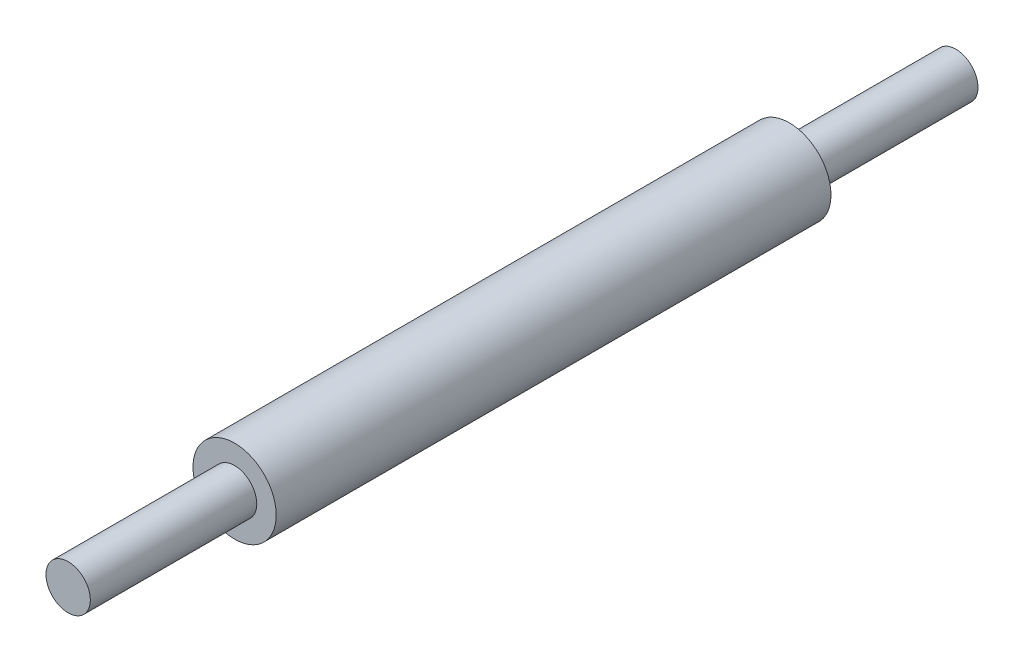
from build123d import *

# Parameters (mm, degrees)
SKETCH1_R           = 0.75
BOSS_EXTRUDE1_DEPTH = 10
SKETCH3_R           = 0.4
BOSS_EXTRUDE2_DEPTH = 3
SKETCH4_R           = 0.4
BOSS_EXTRUDE3_DEPTH = 3


with BuildPart() as part:
    # Sketch1 → Boss-Extrude1 (new body)
    with BuildSketch(Plane.XY):
        Circle(SKETCH1_R)
    extrude(amount=BOSS_EXTRUDE1_DEPTH)

    # Sketch3 → Boss-Extrude2 (add)
    with BuildSketch(Plane.XY.offset(10)):
        Circle(SKETCH3_R)
    extrude(amount=BOSS_EXTRUDE2_DEPTH)

    # Sketch4 → Boss-Extrude3 (add)
    with BuildSketch(Plane(origin=(0, 0, 0), x_dir=(-1, 0, 0), z_dir=(0, 0, -1))):
        Circle(SKETCH4_R)
    extrude(amount=BOSS_EXTRUDE3_DEPTH)


solid = part.part
